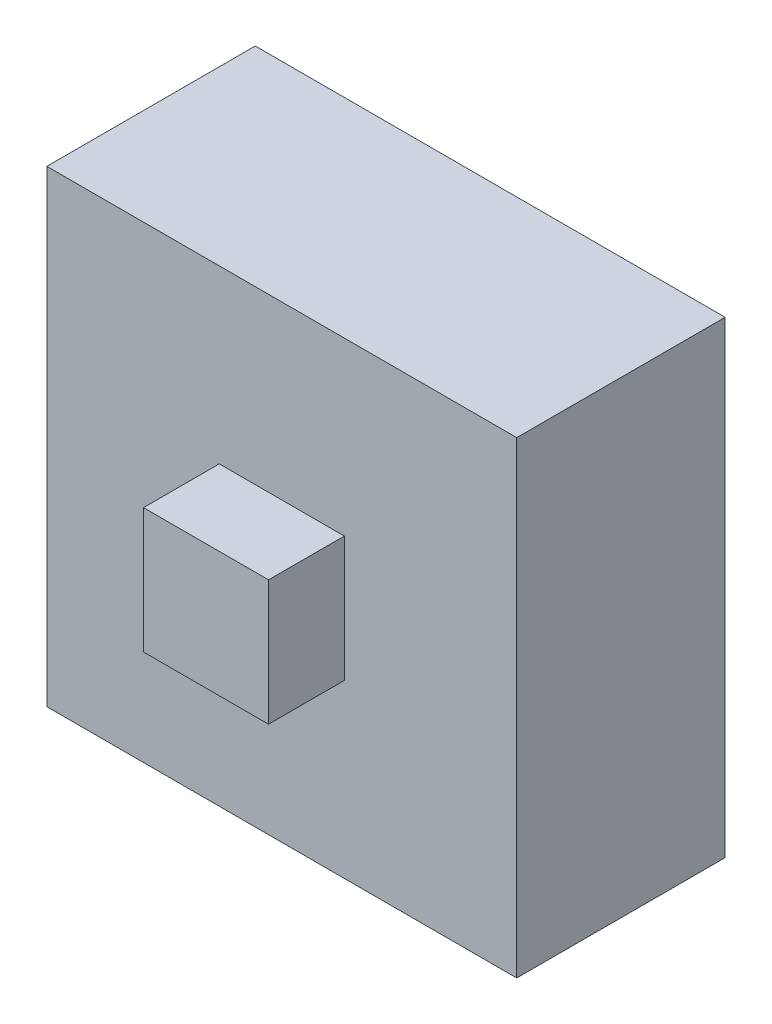
from build123d import *

# Parameters (mm, degrees)
BOSS_EXTRUDE1_DEPTH      = 3
BOSS_EXTRUDE2_START      = 22.115178
SKETCH3_W                = 10.4
SKETCH3_H                = 10.35
BOSS_EXTRUDE2_DEPTH      = 1
BOSS_EXTRUDE2_DEPTH_BACK = 3
CUT_EXTRUDE1_DEPTH       = 4
BOSS_EXTRUDE3_DEPTH      = 2
SKETCH6_W                = 4
SKETCH6_H                = 3.75
BOSS_EXTRUDE4_DEPTH      = 1
SKETCH7_W                = 4
SKETCH7_H                = 3.75
BOSS_EXTRUDE5_DEPTH      = 1
SKETCH8_W                = 3.8
SKETCH8_H                = 4
BOSS_EXTRUDE6_DEPTH      = 1
SKETCH9_W                = 3.8
SKETCH9_H                = 4
BOSS_EXTRUDE7_DEPTH      = 1
CUT_EXTRUDE2_DEPTH       = 3
BOSS_EXTRUDE8_DEPTH      = 3
BOSS_EXTRUDE9_DEPTH      = 6
BOSS_EXTRUDE10_DEPTH     = 7
SKETCH15_W               = 12.4
SKETCH15_H               = 12.35
CUT_EXTRUDE3_DEPTH       = 1.5


with BuildPart() as part:
    # Sketch1 → Boss-Extrude1 (new body)
    with BuildSketch(Plane.XY):
        Polygon((6.141518054, 8.123354813), (2.841518054, 8.123354813), (2.841518054, 5.623354813), (3.641518054, 4.823354813), (5.341518054, 4.823354813), (6.141518054, 5.623354813), align=None)
    extrude(amount=BOSS_EXTRUDE1_DEPTH)

    # Sketch3 → Boss-Extrude2 (add, two sides)
    with BuildSketch(Plane.XY.offset(-22.115178163).offset(BOSS_EXTRUDE2_START)) as boss_extrude2_sk:
        with Locations((4.491518054, 6.473354813)):
            Rectangle(SKETCH3_W, SKETCH3_H)
        Polygon((2.841518054, 8.123354813), (2.841518054, 5.623354813), (3.641518054, 4.823354813), (5.341518054, 4.823354813), (6.141518054, 5.623354813), (6.141518054, 8.123354813), align=None, mode=Mode.SUBTRACT)
    extrude(amount=BOSS_EXTRUDE2_DEPTH)
    extrude(boss_extrude2_sk.sketch, amount=-BOSS_EXTRUDE2_DEPTH_BACK)

    # Sketch4 → Cut-Extrude1 (cut)
    with BuildSketch(Plane.XY.offset(1)):
        with BuildLine():
            Line((-0.708481946, 4.598354813), (-0.708481946, 1.298354813))
            Line((-0.708481946, 1.298354813), (2.591518054, 1.298354813))
            ThreePointArc((2.591518054, 1.298354813), (1.624970432, 3.631807191), (-0.708481946, 4.598354813))
        make_face()
        with BuildLine():
            Line((9.691518054, 1.298354813), (6.391518054, 1.298354813))
            ThreePointArc((6.391518054, 1.298354813), (7.358065676, 3.631807191), (9.691518054, 4.598354813))
            Line((9.691518054, 4.598354813), (9.691518054, 1.298354813))
        make_face()
        with BuildLine():
            Line((9.691518054, 8.348354813), (9.691518054, 11.648354813))
            Line((9.691518054, 11.648354813), (6.391518054, 11.648354813))
            ThreePointArc((6.391518054, 11.648354813), (7.358065676, 9.314902435), (9.691518054, 8.348354813))
        make_face()
        with BuildLine():
            Line((-0.708481946, 8.348354813), (-0.708481946, 11.648354813))
            Line((-0.708481946, 11.648354813), (2.591518054, 11.648354813))
            ThreePointArc((2.591518054, 11.648354813), (1.624970432, 9.314902435), (-0.708481946, 8.348354813))
        make_face()
    extrude(amount=-CUT_EXTRUDE1_DEPTH, mode=Mode.SUBTRACT)

    # Sketch5 → Boss-Extrude3 (add)
    with BuildSketch(Plane.XY.offset(3)):
        Polygon((2.841518054, 5.623354813), (3.641518054, 4.823354813), (2.841518054, 4.823354813), align=None)
        Polygon((5.341518054, 4.823354813), (6.141518054, 5.623354813), (6.141518054, 4.823354813), align=None)
    extrude(amount=-BOSS_EXTRUDE3_DEPTH)

    # Sketch6 → Boss-Extrude4 (add)
    with BuildSketch(Plane.ZY.offset(0.708481946)):
        with Locations((-1, 6.473354813)):
            Rectangle(SKETCH6_W, SKETCH6_H)
    extrude(amount=BOSS_EXTRUDE4_DEPTH)

    # Sketch7 → Boss-Extrude5 (add)
    with BuildSketch(Plane(origin=(9.691518054, 0, 0), x_dir=(0, 0, -1), z_dir=(1, 0, 0))):
        with Locations((1, 6.473354813)):
            Rectangle(SKETCH7_W, SKETCH7_H)
    extrude(amount=BOSS_EXTRUDE5_DEPTH)

    # Sketch8 → Boss-Extrude6 (add)
    with BuildSketch(Plane(origin=(0, 11.648354813, 0), x_dir=(1, 0, 0), z_dir=(0, 1, 0))):
        with Locations((4.491518054, 1)):
            Rectangle(SKETCH8_W, SKETCH8_H)
    extrude(amount=BOSS_EXTRUDE6_DEPTH)

    # Sketch9 → Boss-Extrude7 (add)
    with BuildSketch(Plane.XZ.offset(-1.298354813)):
        with Locations((4.491518054, -1)):
            Rectangle(SKETCH9_W, SKETCH9_H)
    extrude(amount=BOSS_EXTRUDE7_DEPTH)

    # Sketch10 → Cut-Extrude2 (cut)
    with BuildSketch(Plane(origin=(0, 0, -3), x_dir=(-1, 0, 0), z_dir=(0, 0, -1))):
        Polygon((-6.641518054, 6.873354813), (-6.641518054, 8.623354813), (-4.491518054, 8.623354813), (-2.341518054, 8.623354813), (-2.341518054, 6.873354813), (-2.341518054, 5.623354813), (-3.641518054, 4.323354813), (-4.491518054, 4.323354813), (-5.341518054, 4.323354813), (-5.841518054, 4.823354813), (-6.641518054, 5.623354813), align=None)
    extrude(amount=-CUT_EXTRUDE2_DEPTH, mode=Mode.SUBTRACT)

    # Sketch11 → Boss-Extrude8 (add)
    with BuildSketch(Plane(origin=(0, 0, -3), x_dir=(-1, 0, 0), z_dir=(0, 0, -1))):
        with BuildLine():
            Line((0.708481946, 4.598354813), (1.708481946, 4.598354813))
            Line((1.708481946, 4.598354813), (1.708481946, 8.348354813))
            Line((1.708481946, 8.348354813), (0.708481946, 8.348354813))
            ThreePointArc((0.708481946, 8.348354813), (-1.624970432, 9.314902435), (-2.591518054, 11.648354813))
            Line((-2.591518054, 11.648354813), (-2.591518054, 12.648354813))
            Line((-2.591518054, 12.648354813), (-6.391518054, 12.648354813))
            Line((-6.391518054, 12.648354813), (-6.391518054, 11.648354813))
            ThreePointArc((-6.391518054, 11.648354813), (-7.358065676, 9.314902435), (-9.691518054, 8.348354813))
            Line((-9.691518054, 8.348354813), (-10.691518054, 8.348354813))
            Line((-10.691518054, 8.348354813), (-10.691518054, 4.598354813))
            Line((-10.691518054, 4.598354813), (-9.691518054, 4.598354813))
            ThreePointArc((-9.691518054, 4.598354813), (-7.358065676, 3.631807191), (-6.391518054, 1.298354813))
            Line((-6.391518054, 1.298354813), (-6.391518054, 0.298354813))
            Line((-6.391518054, 0.298354813), (-2.591518054, 0.298354813))
            Line((-2.591518054, 0.298354813), (-2.591518054, 1.298354813))
            ThreePointArc((-2.591518054, 1.298354813), (-1.624970432, 3.631807191), (0.708481946, 4.598354813))
        make_face()
        Polygon((-6.641518054, 5.623354813), (-5.341518054, 4.323354813), (-3.641518054, 4.323354813), (-2.341518054, 5.623354813), (-2.341518054, 8.623354813), (-6.641518054, 8.623354813), align=None, mode=Mode.SUBTRACT)
    extrude(amount=BOSS_EXTRUDE8_DEPTH)

    # Sketch13 → Boss-Extrude9 (add)
    with BuildSketch(Plane(origin=(0, 0, -6), x_dir=(-1, 0, 0), z_dir=(0, 0, -1))):
        Polygon((-2.341518054, 8.623354813), (-6.641518054, 8.623354813), (-6.641518054, 5.623354813), (-5.341518054, 4.323354813), (-3.641518054, 4.323354813), (-2.341518054, 5.623354813), align=None)
        Polygon((-6.391518054, 7.123354813), (-6.391518054, 8.373354813), (-4.491518054, 8.373354813), (-2.591518054, 8.373354813), (-2.591518054, 7.123354813), (-2.591518054, 5.726908204), (-3.168294749, 5.150131508), (-3.745071444, 4.573354813), (-4.491518054, 4.573354813), (-5.237964663, 4.573354813), (-5.814741358, 5.150131508), (-6.391518054, 5.726908204), align=None, mode=Mode.SUBTRACT)
    extrude(amount=-BOSS_EXTRUDE9_DEPTH)

    # Sketch14 → Boss-Extrude10 (add)
    with BuildSketch(Plane(origin=(0, 0, -6), x_dir=(-1, 0, 0), z_dir=(0, 0, -1))):
        Polygon((1.708481946, 4.598354813), (1.708481946, 8.348354813), (1.708481946, 12.648354813), (-2.591518054, 12.648354813), (-6.391518054, 12.648354813), (-10.691518054, 12.648354813), (-10.691518054, 8.348354813), (-10.691518054, 4.598354813), (-10.691518054, 0.298354813), (-6.391518054, 0.298354813), (-2.591518054, 0.298354813), (1.708481946, 0.298354813), align=None)
        Polygon((-6.391518054, 5.726908204), (-5.237964663, 4.573354813), (-3.745071444, 4.573354813), (-2.591518054, 5.726908204), (-2.591518054, 8.373354813), (-6.391518054, 8.373354813), align=None, mode=Mode.SUBTRACT)
    extrude(amount=-BOSS_EXTRUDE10_DEPTH)

    # Sketch15 → Cut-Extrude3 (cut)
    with BuildSketch(Plane(origin=(0, 0, -6), x_dir=(-1, 0, 0), z_dir=(0, 0, -1))):
        with Locations((-4.491518054, 6.473354813)):
            Rectangle(SKETCH15_W, SKETCH15_H)
    extrude(amount=-CUT_EXTRUDE3_DEPTH, mode=Mode.SUBTRACT)


solid = part.part
